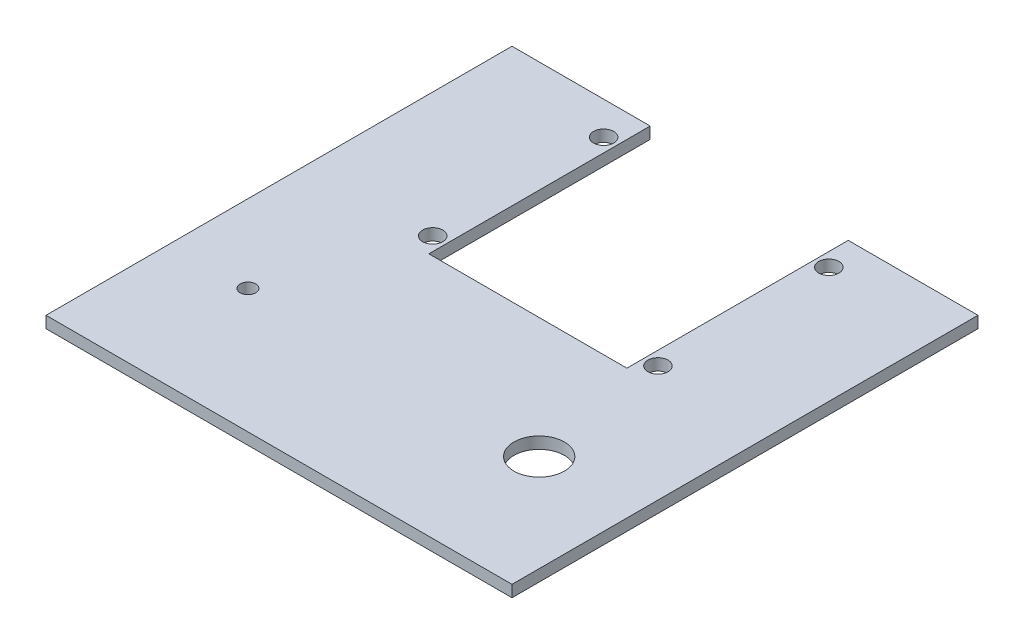
from build123d import *

# Parameters (mm, degrees)
SKETCH_1_W          = 120
SKETCH_1_H          = 120
EXTRUDE_1_DEPTH     = 3
SKETCH_2_R          = 2
SKETCH_2_R_2        = 6.5
SKETCH_2_R_3        = 2.6
SKETCH_2_W          = 51
SKETCH_2_H          = 57
CUT_EXTRUDE_1_DEPTH = 3


with BuildPart() as part:
    # 草图1 → 凸台-拉伸1 (new body)
    with BuildSketch(Plane(origin=(0, 0, 0), x_dir=(1, 0, 0), z_dir=(0, 1, 0))):
        with Locations((60, -60)):
            Rectangle(SKETCH_1_W, SKETCH_1_H)
    extrude(amount=EXTRUDE_1_DEPTH)

    # 草图2 → 切除-拉伸1 (cut)
    with BuildSketch(Plane(origin=(0, 3, 0), x_dir=(1, 0, 0), z_dir=(0, 1, 0))):
        with Locations((20, -88)):
            Circle(SKETCH_2_R)
        with Locations((95, -88)):
            Circle(SKETCH_2_R_2)
        with Locations((32.086613668, -8.5)):
            Circle(SKETCH_2_R_3)
        with Locations((32.086613668, -52.5)):
            Circle(SKETCH_2_R_3)
        with Locations((90.086613668, -8.5)):
            Circle(SKETCH_2_R_3)
        with Locations((90.086613668, -52.5)):
            Circle(SKETCH_2_R_3)
        with Locations((61.086613668, -28.5)):
            Rectangle(SKETCH_2_W, SKETCH_2_H)
    extrude(amount=-CUT_EXTRUDE_1_DEPTH, mode=Mode.SUBTRACT)


solid = part.part
